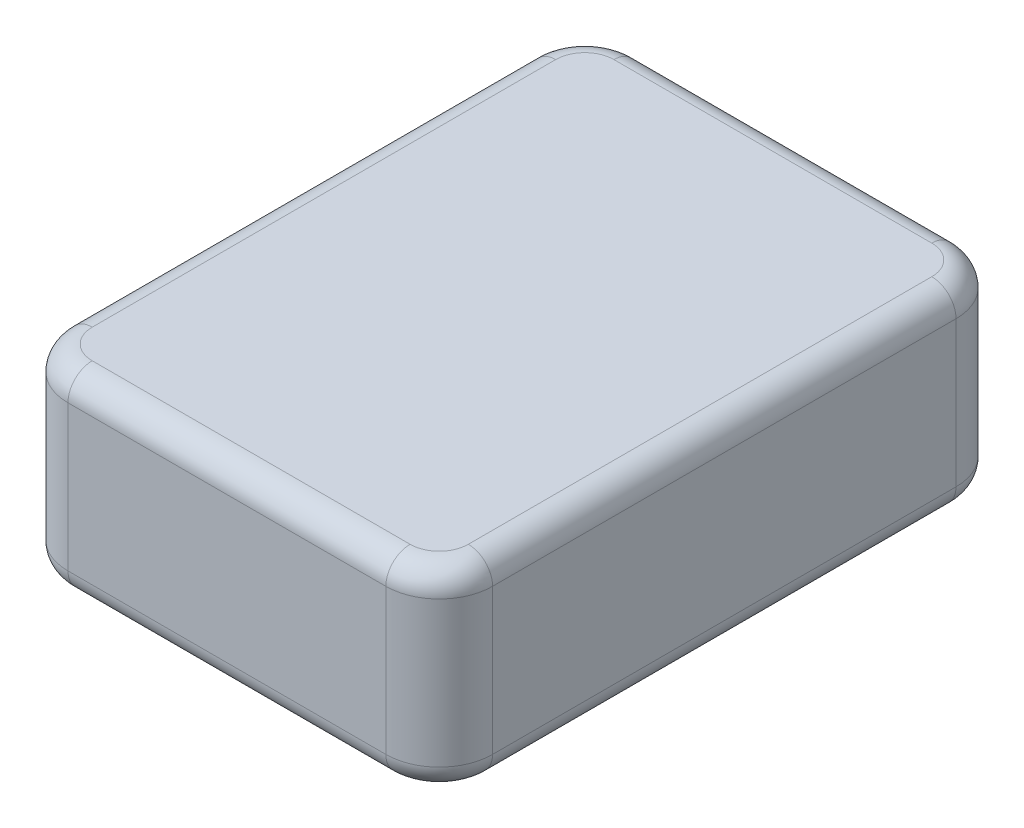
from build123d import *

# Parameters (mm, degrees)
SKETCH1_W           = 444.5
SKETCH1_H           = 596.9
BOSS_EXTRUDE1_DEPTH = 203.2
FILLET1_R           = 55.88
FILLET2_R           = 25.4


with BuildPart() as part:
    # Sketch1 → Boss-Extrude1 (new body)
    with BuildSketch(Plane(origin=(0, 0, 0), x_dir=(1, 0, 0), z_dir=(0, 1, 0))):
        with Locations((222.25, 298.45)):
            Rectangle(SKETCH1_W, SKETCH1_H)
    extrude(amount=BOSS_EXTRUDE1_DEPTH)

    # Fillet1
    fillet1_edges = [part.edges().sort_by_distance(p)[0] for p in [
        (0, 101.6, 0),
        (0, 101.6, -596.9),
        (444.5, 101.6, -596.9),
        (444.5, 101.6, 0),
    ]]
    fillet(fillet1_edges, radius=FILLET1_R)

    # Fillet2
    fillet2_edges = [part.edges().sort_by_distance(p)[0] for p in [
        (222.25, 0, -596.9),
        (222.25, 203.2, -596.9),
        (222.25, 0, 0),
        (0, 0, -298.45),
        (444.5, 0, -298.45),
        (16.366873067, 0, -16.366873067),
        (428.133126933, 0, -16.366873067),
        (16.366873067, 0, -580.533126933),
        (428.133126933, 0, -580.533126933),
        (444.5, 203.2, -298.45),
        (222.25, 203.2, 0),
        (0, 203.2, -298.45),
        (16.366873067, 203.2, -16.366873067),
        (428.133126933, 203.2, -16.366873067),
        (16.366873067, 203.2, -580.533126933),
        (428.133126933, 203.2, -580.533126933),
    ]]
    fillet(fillet2_edges, radius=FILLET2_R)


solid = part.part
